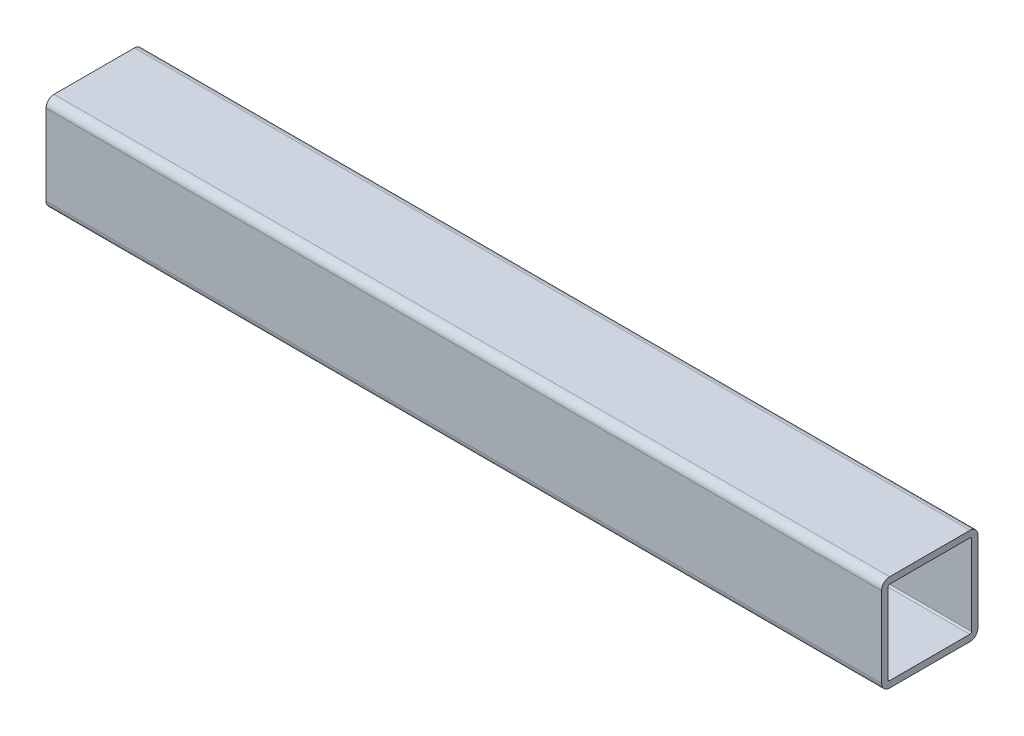
from build123d import *

# Parameters (mm, degrees)
EXTRUDE_THIN1_DEPTH = 165.1


with BuildPart() as part:
    # Sketch1 → Extrude-Thin1 (new body, symmetric)
    with BuildSketch(Plane(origin=(0, 0, 0), x_dir=(0, 0, -1), z_dir=(1, 0, 0))):
        with BuildLine():
            Line((-15.875, 19.05), (15.875, 19.05))
            ThreePointArc((15.875, 19.05), (18.12006403, 18.12006403), (19.05, 15.875))
            Line((19.05, 15.875), (19.05, -15.875))
            ThreePointArc((19.05, -15.875), (18.12006403, -18.12006403), (15.875, -19.05))
            Line((15.875, -19.05), (-15.875, -19.05))
            ThreePointArc((-15.875, -19.05), (-18.12006403, -18.12006403), (-19.05, -15.875))
            Line((-19.05, -15.875), (-19.05, 15.875))
            ThreePointArc((-19.05, 15.875), (-18.12006403, 18.12006403), (-15.875, 19.05))
        make_face()
        with BuildLine():
            Line((-15.875, 16.51), (15.875, 16.51))
            ThreePointArc((15.875, 16.51), (16.324012806, 16.324012806), (16.51, 15.875))
            Line((16.51, 15.875), (16.51, -15.875))
            ThreePointArc((16.51, -15.875), (16.324012806, -16.324012806), (15.875, -16.51))
            Line((15.875, -16.51), (-15.875, -16.51))
            ThreePointArc((-15.875, -16.51), (-16.324012806, -16.324012806), (-16.51, -15.875))
            Line((-16.51, -15.875), (-16.51, 15.875))
            ThreePointArc((-16.51, 15.875), (-16.324012806, 16.324012806), (-15.875, 16.51))
        make_face(mode=Mode.SUBTRACT)
    extrude(amount=EXTRUDE_THIN1_DEPTH, both=True)


solid = part.part
